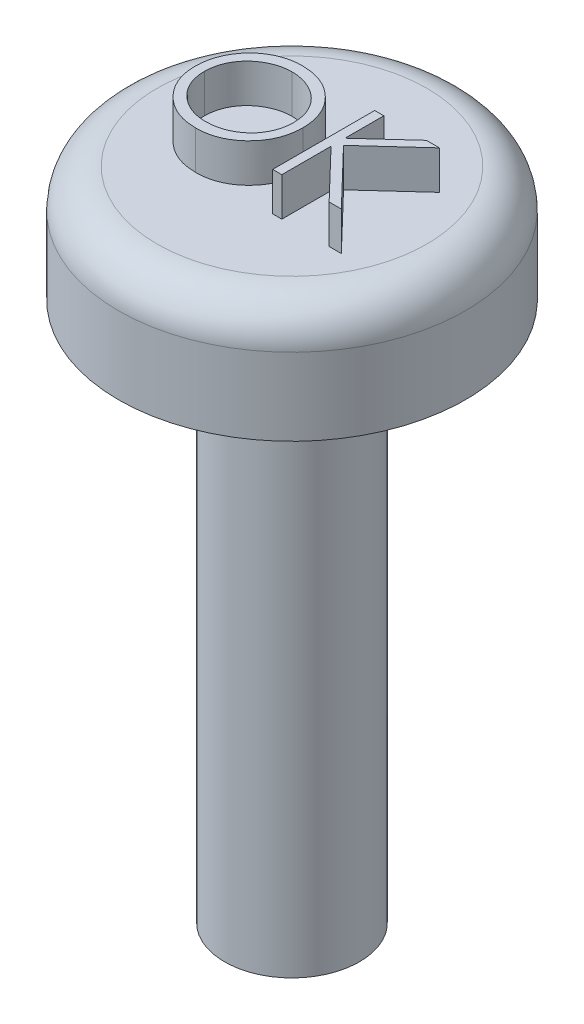
from build123d import *

# Parameters (mm, degrees)
SKETCH1_R           = 4.5
BOSS_EXTRUDE1_DEPTH = 3
FILLET1_R           = 1
SKETCH6_R           = 1.75
BOSS_EXTRUDE3_DEPTH = 14
BOSS_EXTRUDE4_DEPTH = 1


with BuildPart() as part:
    # Sketch1 → Boss-Extrude1 (new body)
    with BuildSketch(Plane(origin=(0, 115.601531763, -5.053e-06), x_dir=(1, 0, 0), z_dir=(0, 1, -4.4e-08))):
        with Locations((40.91030477, -143.155151275)):
            Circle(SKETCH1_R)
    extrude(amount=BOSS_EXTRUDE1_DEPTH)

    # Fillet1
    fillet1_edges = [part.edges().sort_by_distance(p)[0] for p in [
        (36.41030477, 118.601538021, 143.155146091),
    ]]
    fillet(fillet1_edges, radius=FILLET1_R)

    # Sketch6 → Boss-Extrude3 (add)
    with BuildSketch(Plane(origin=(0, 115.601531763, -5.053e-06), x_dir=(-1, 0, 0), z_dir=(0, -1, 4.4e-08))):
        with Locations((-40.91030477, -143.155151275)):
            Circle(SKETCH6_R)
    extrude(amount=BOSS_EXTRUDE3_DEPTH)

    # Sketch7 → Boss-Extrude4 (add)
    with BuildSketch(Plane(origin=(0, 118.601531763, -5.184e-06), x_dir=(1, 0, 0), z_dir=(0, 1, -4.4e-08))):
        with BuildLine():
            add(Edge.make_bspline(
                [(39.781937709, -141.764742389), (39.830929551, -141.76598327), (39.927153571, -141.768420461), (40.068573285, -141.787076688), (40.203582672, -141.81935237), (40.333281527, -141.862338077), (40.45611848, -141.91968038), (40.573018119, -141.988989986), (40.683702303, -142.070993023), (40.786679181, -142.165055594), (40.880913899, -142.267399038), (40.96393704, -142.376617458), (41.033516631, -142.492050481), (41.090655886, -142.613351228), (41.135482812, -142.740245371), (41.16641566, -142.873409408), (41.186174857, -143.011980537), (41.188484879, -143.106494893), (41.189656726, -143.154440907)],
                knots=[0, 0, 0, 0, 0.000146952, 0.000288625, 0.000426954, 0.000562883, 0.000697813, 0.000832796, 0.000969967, 0.001110296, 0.00125059, 0.001386805, 0.001521151, 0.001654161, 0.00178843, 0.001924058, 0.002063701, 0.002207476, 0.002207476, 0.002207476, 0.002207476], degree=3))
            add(Edge.make_bspline(
                [(41.189656726, -143.154440907), (41.188485051, -143.202033739), (41.186175543, -143.295844723), (41.166393194, -143.433536493), (41.135368152, -143.565896722), (41.091072165, -143.692704448), (41.034205286, -143.814093439), (40.964162388, -143.929744292), (40.88165683, -144.039694918), (40.787762365, -144.142740802), (40.685405625, -144.237232938), (40.575618459, -144.319570421), (40.460869938, -144.390421396), (40.339683432, -144.446954293), (40.213666142, -144.492139018), (40.08169022, -144.522946066), (39.944374075, -144.542817819), (39.850733494, -144.545099673), (39.803138297, -144.546259483)],
                knots=[0, 0, 0, 0, 0.000142716, 0.000281309, 0.000416421, 0.000550016, 0.000683505, 0.000817851, 0.000954912, 0.001095241, 0.001235536, 0.001372174, 0.001506342, 0.001639351, 0.001772621, 0.001907218, 0.002045287, 0.002188002, 0.002188002, 0.002188002, 0.002188002], degree=3))
            add(Edge.make_bspline(
                [(39.803138297, -144.546259483), (39.755192532, -144.545088221), (39.660678666, -144.54277935), (39.521933407, -144.522987455), (39.388675827, -144.492037779), (39.261287002, -144.447807431), (39.139695894, -144.390644406), (39.023664701, -144.320942286), (38.913659155, -144.238235697), (38.810591287, -144.144371679), (38.716286834, -144.042188423), (38.634069925, -143.932700623), (38.564352131, -143.818056319), (38.50738104, -143.697937357), (38.46227755, -143.572924422), (38.431506646, -143.442183608), (38.41159792, -143.306460291), (38.409303721, -143.214050481), (38.408139632, -143.16716126)],
                knots=[0, 0, 0, 0, 0.000143775, 0.000283418, 0.000419562, 0.000553657, 0.000687146, 0.000821946, 0.000959007, 0.001099336, 0.001239631, 0.001375527, 0.001509419, 0.001641471, 0.001773742, 0.001907308, 0.002043802, 0.0021844, 0.0021844, 0.0021844, 0.0021844], degree=3))
            add(Edge.make_bspline(
                [(38.408139632, -143.16716126), (38.408543791, -143.135688944), (38.40934701, -143.073141351), (38.419016921, -142.980260052), (38.433048683, -142.888872471), (38.453158462, -142.799238481), (38.479459306, -142.711577499), (38.510492683, -142.625284958), (38.548396019, -142.541235357), (38.59124389, -142.459030531), (38.639066804, -142.379951936), (38.691889543, -142.305203679), (38.747856756, -142.234158521), (38.809212417, -142.168657512), (38.873934373, -142.106795165), (38.943072551, -142.049522158), (39.016205081, -141.996322047), (39.093646642, -141.948379289), (39.173489029, -141.905018514), (39.255794688, -141.867809139), (39.339445787, -141.835873128), (39.424834122, -141.809988695), (39.511732943, -141.789553763), (39.600331912, -141.77563868), (39.690560442, -141.765944106), (39.75134757, -141.765144685), (39.781937709, -141.764742389)],
                knots=[0, 0, 0, 0, 9.438e-05, 0.000187569, 0.000279848, 0.000371657, 0.000462884, 0.000554264, 0.000646556, 0.00073925, 0.000832238, 0.000923551, 0.001013693, 0.001103328, 0.001192553, 0.001282131, 0.001372457, 0.00146364, 0.001555178, 0.001644836, 0.001734413, 0.00182361, 0.001912319, 0.002001981, 0.002092533, 0.002184264, 0.002184264, 0.002184264, 0.002184264], degree=3))
        make_face()
        with BuildLine():
            add(Edge.make_bspline(
                [(39.793598032, -142.036109911), (39.768489351, -142.036415989), (39.718512029, -142.037025218), (39.6442136, -142.045050193), (39.570892316, -142.056487669), (39.498533037, -142.072802271), (39.42743852, -142.095030335), (39.356946081, -142.12061245), (39.287698534, -142.151773631), (39.219924487, -142.186980378), (39.154220829, -142.225948908), (39.092223132, -142.269016851), (39.033770895, -142.31517421), (38.979007235, -142.364528706), (38.928092956, -142.417331679), (38.88002595, -142.472782628), (38.836732873, -142.532466498), (38.797056276, -142.594764841), (38.761550826, -142.659596512), (38.729978206, -142.726278968), (38.704151843, -142.795356148), (38.683089213, -142.866078636), (38.665626856, -142.938334424), (38.654564306, -143.012671643), (38.646451153, -143.088716757), (38.645876746, -143.140107802), (38.645586213, -143.16610123)],
                knots=[0, 0, 0, 0, 7.5292e-05, 0.000149864, 0.00022393, 0.000297861, 0.000372133, 0.000447257, 0.000522705, 0.000599749, 0.000676284, 0.000751707, 0.000826039, 0.000899591, 0.000972681, 0.001045978, 0.001119549, 0.001193655, 0.001267426, 0.001341167, 0.0014148, 0.001488412, 0.001562462, 0.001637575, 0.001713729, 0.00179167, 0.00179167, 0.00179167, 0.00179167], degree=3))
            add(Edge.make_bspline(
                [(38.645586213, -143.16610123), (38.646549948, -143.204323861), (38.648445913, -143.279519602), (38.66504479, -143.389713377), (38.690612592, -143.495613451), (38.728302387, -143.59664037), (38.775436483, -143.693662536), (38.833665144, -143.785819258), (38.902652667, -143.873135443), (38.981017357, -143.95500151), (39.066683927, -144.029724231), (39.15764974, -144.095313236), (39.252940265, -144.150807889), (39.352803996, -144.196017676), (39.45670779, -144.231842061), (39.565321177, -144.25639436), (39.677920631, -144.272553186), (39.754672972, -144.274104972), (39.793598032, -144.274891962)],
                knots=[0, 0, 0, 0, 0.000114606, 0.000225465, 0.000333574, 0.000440894, 0.000548272, 0.000656647, 0.000767237, 0.000881574, 0.000996152, 0.001107795, 0.001217519, 0.00132639, 0.001436175, 0.001546614, 0.001660023, 0.001776724, 0.001776724, 0.001776724, 0.001776724], degree=3))
            add(Edge.make_bspline(
                [(39.793598032, -144.274891962), (39.819761167, -144.274532503), (39.871650522, -144.273819589), (39.948829875, -144.266639042), (40.024618797, -144.255124474), (40.098910985, -144.238545942), (40.171622122, -144.217797161), (40.243055694, -144.193147272), (40.31245083, -144.162394219), (40.380682969, -144.128415708), (40.445994414, -144.089680589), (40.508341989, -144.048074369), (40.566154188, -144.001984995), (40.620876879, -143.953363791), (40.672000191, -143.901230406), (40.719178411, -143.845652619), (40.762252678, -143.786279622), (40.801914208, -143.724075774), (40.837295246, -143.659066702), (40.868122303, -143.592142481), (40.89427532, -143.523467905), (40.915387939, -143.452943919), (40.931932306, -143.380704468), (40.943332007, -143.306652825), (40.951306125, -143.230937132), (40.951907165, -143.179726003), (40.952210145, -143.153910892)],
                knots=[0, 0, 0, 0, 7.8471e-05, 0.000155631, 0.000232315, 0.000308314, 0.000383811, 0.000459075, 0.000534795, 0.000611356, 0.000687621, 0.000762445, 0.000836033, 0.000909231, 0.000981942, 0.001054895, 0.001127725, 0.001201831, 0.001276067, 0.001349584, 0.001422723, 0.001496334, 0.001570264, 0.001644854, 0.001721008, 0.001798419, 0.001798419, 0.001798419, 0.001798419], degree=3))
            add(Edge.make_bspline(
                [(40.952210145, -143.153910892), (40.951906923, -143.128272386), (40.951305425, -143.077413686), (40.943335816, -143.002226044), (40.931920262, -142.928707247), (40.915468691, -142.85714592), (40.894264111, -142.787523821), (40.868117736, -142.719906339), (40.837285992, -142.654041572), (40.801901203, -142.590092312), (40.762126146, -142.528728075), (40.718663236, -142.470064347), (40.67076205, -142.41520281), (40.619791186, -142.362789083), (40.564477481, -142.313941036), (40.505071497, -142.268642464), (40.442294431, -142.225800167), (40.375825628, -142.187151677), (40.30722752, -142.151459965), (40.236837802, -142.120880933), (40.165453899, -142.094897248), (40.093257338, -142.072735018), (40.019640444, -142.056551567), (39.945100645, -142.045039886), (39.869741068, -142.037028011), (39.819059587, -142.036416915), (39.793598032, -142.036109911)],
                knots=[0, 0, 0, 0, 7.6881e-05, 0.000152508, 0.000226574, 0.000299988, 0.000372585, 0.000444733, 0.000517289, 0.000590596, 0.000663809, 0.000736527, 0.000809423, 0.000882134, 0.000955727, 0.00103057, 0.00110613, 0.001183578, 0.001261092, 0.001337996, 0.001413617, 0.001488903, 0.001564385, 0.001639498, 0.001715125, 0.001791477, 0.001791477, 0.001791477, 0.001791477], degree=3))
        make_face(mode=Mode.SUBTRACT)
        Polygon((41.732391769, -141.83258427), (41.96983835, -141.83258427), (41.96983835, -142.840142196), (43.07279892, -141.83258427), (43.411478307, -141.83258427), (42.111352272, -143.019817176), (43.513241128, -144.478417603), (43.196822358, -144.478417603), (41.96983835, -143.201612214), (41.96983835, -144.478417603), (41.732391769, -144.478417603), align=None)
    extrude(amount=BOSS_EXTRUDE4_DEPTH)


solid = part.part
